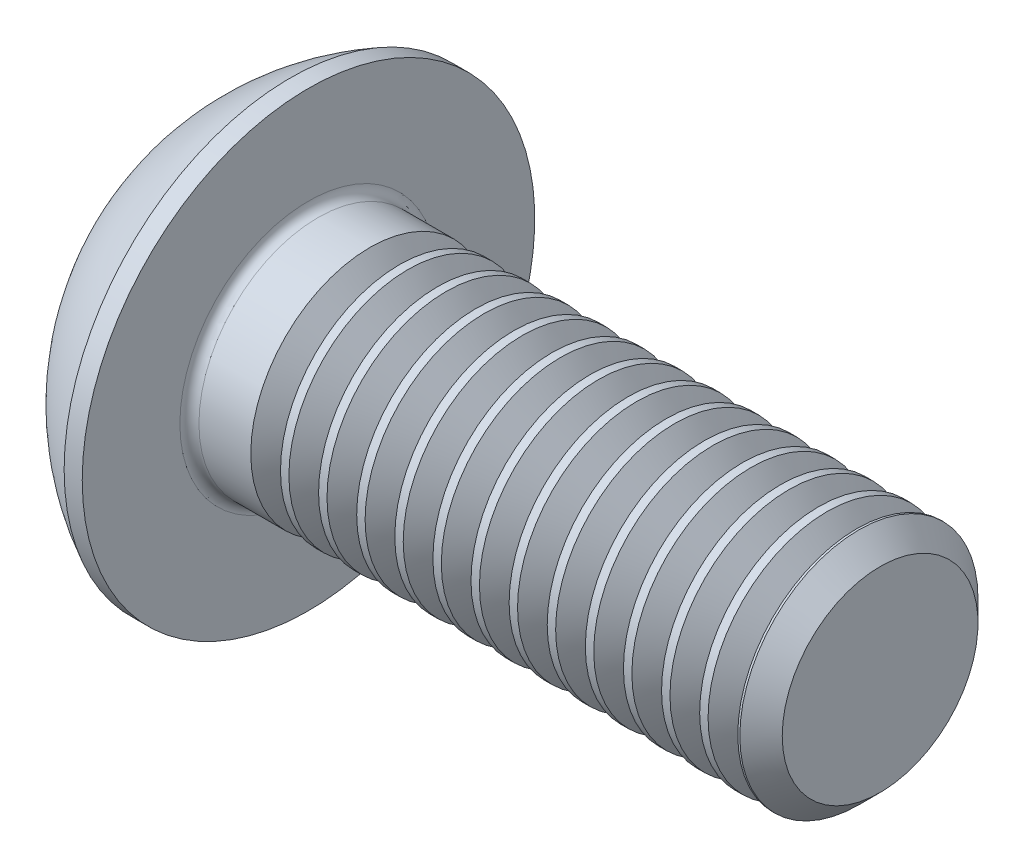
from build123d import *

# Parameters (mm, degrees)
FILLET1_R       = 0.2
HEX_2_DEPTH     = 1.56
THDSCHPAT_COUNT = 13
THDSCHPAT_PITCH = 0.8


with BuildPart() as part:
    # BodySke → BaseBody (revolve)
    with BuildSketch(Plane.XY):
        with BuildLine():
            Line((14.75, 0), (14.75, 2.055))
            Line((14.75, 2.055), (14.305, 2.5))
            Line((14.305, 2.5), (2.75, 2.5))
            Line((2.75, 2.5), (2.75, 4.75))
            Line((2.75, 4.75), (2.37, 4.75))
            ThreePointArc((2.37, 4.75), (0.992680215, 3.754414901), (0, 2.375))
            Line((0, 2.375), (0, 0))
            Line((0, 0), (14.75, 0))
        make_face()
    revolve(axis=Axis((0, 0, 0), (1, 0, 0)))

    # Fillet1
    fillet1_edges = [part.edges().sort_by_distance(p)[0] for p in [
        (2.75, -2.5, 0),
    ]]
    fillet(fillet1_edges, radius=FILLET1_R)

    # Sketch2 → PreBroach (revolve, cut)
    with BuildSketch(Plane.XY):
        Polygon((0, 1.5), (1.56, 1.5), (2.426025404, 0), (0, 0), align=None)
    revolve(axis=Axis((0, 0, 0), (1, 0, 0)), mode=Mode.SUBTRACT)

    # Sketch3 → Hex 2 (cut)
    with BuildSketch(Plane(origin=(0, 0, 0), x_dir=(0, 0, -1), z_dir=(1, 0, 0))):
        Polygon((-1.5, -0.866025404), (-1.5, 0.866025404), (0, 1.732050808), (1.5, 0.866025404), (1.5, -0.866025404), (0, -1.732050808), align=None)
    extrude(amount=HEX_2_DEPTH, mode=Mode.SUBTRACT)

    # ThdSchSke → ThreadSchematic (revolve, cut)
    with BuildSketch(Plane.XY):
        Polygon((4.35, -2.055), (4.038407645, -2.5), (4.038407645, -3.125), (4.661592355, -3.125), (4.661592355, -2.5), align=None)
    threadschematic = revolve(axis=Axis((-3.175, 0, 0), (1, 0, 0)), mode=Mode.SUBTRACT)

    # ThdSchPat: ThreadSchematic ×13
    with Locations(*[(i * THDSCHPAT_PITCH, 0, 0) for i in range(1, THDSCHPAT_COUNT)]):
        add(threadschematic, mode=Mode.SUBTRACT)


solid = part.part
